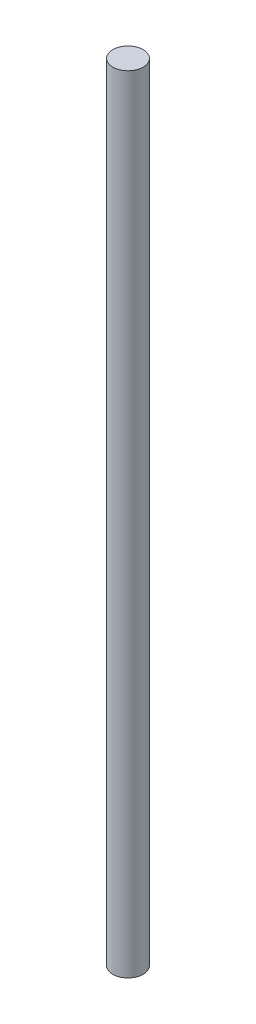
from build123d import *

# Parameters (mm, degrees)
SKETCH1_R           = 2.332714882
BOSS_EXTRUDE1_DEPTH = 109.655614
SKETCH1_2_R         = 2.332714882
BOSS_EXTRUDE3_DEPTH = 11


with BuildPart() as part:
    # Sketch1 → Boss-Extrude1 (new body)
    with BuildSketch(Plane(origin=(0, 0, 0), x_dir=(1, 0, 0), z_dir=(0, 1, 0))):
        Circle(SKETCH1_R)
    extrude(amount=-BOSS_EXTRUDE1_DEPTH)

    # Sketch1_2 → Boss-Extrude3 (add)
    with BuildSketch(Plane(origin=(0, 0, 0), x_dir=(1, 0, 0), z_dir=(0, 1, 0))):
        Circle(SKETCH1_2_R)
    extrude(amount=BOSS_EXTRUDE3_DEPTH)


solid = part.part
